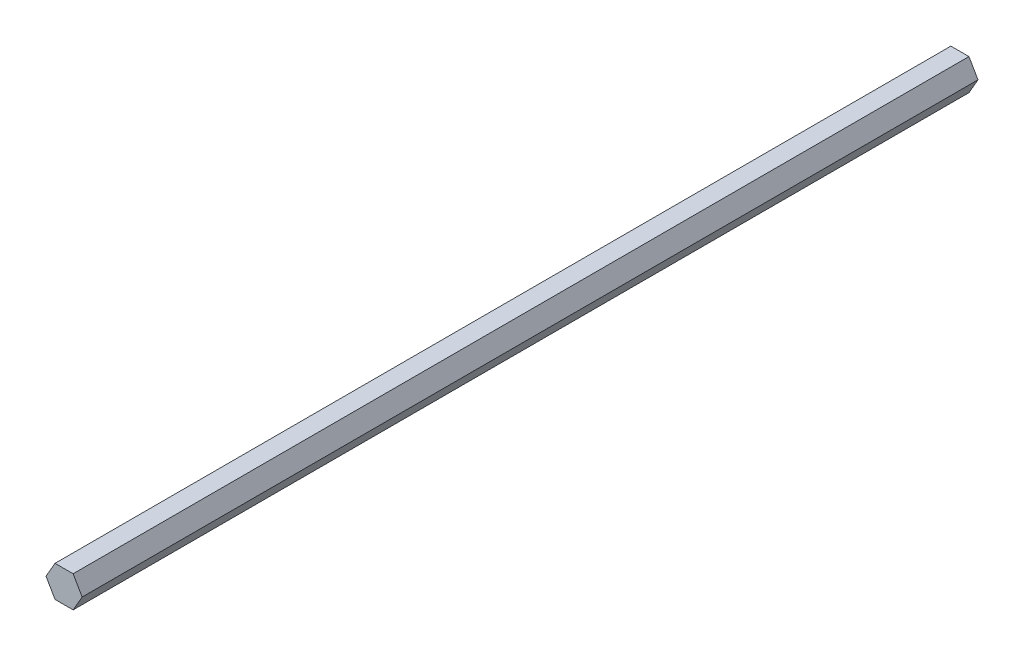
from build123d import *

# Parameters (mm, degrees)
BOSS_EXTRUDE1_DEPTH = 363.18


with BuildPart() as part:
    # Sketch1 → Boss-Extrude1 (new body)
    with BuildSketch(Plane.XY):
        Polygon((-3.665, 6.34796621), (-7.33, 0), (-3.665, -6.34796621), (3.665, -6.34796621), (7.33, 0), (3.665, 6.34796621), align=None)
    extrude(amount=BOSS_EXTRUDE1_DEPTH)


solid = part.part
